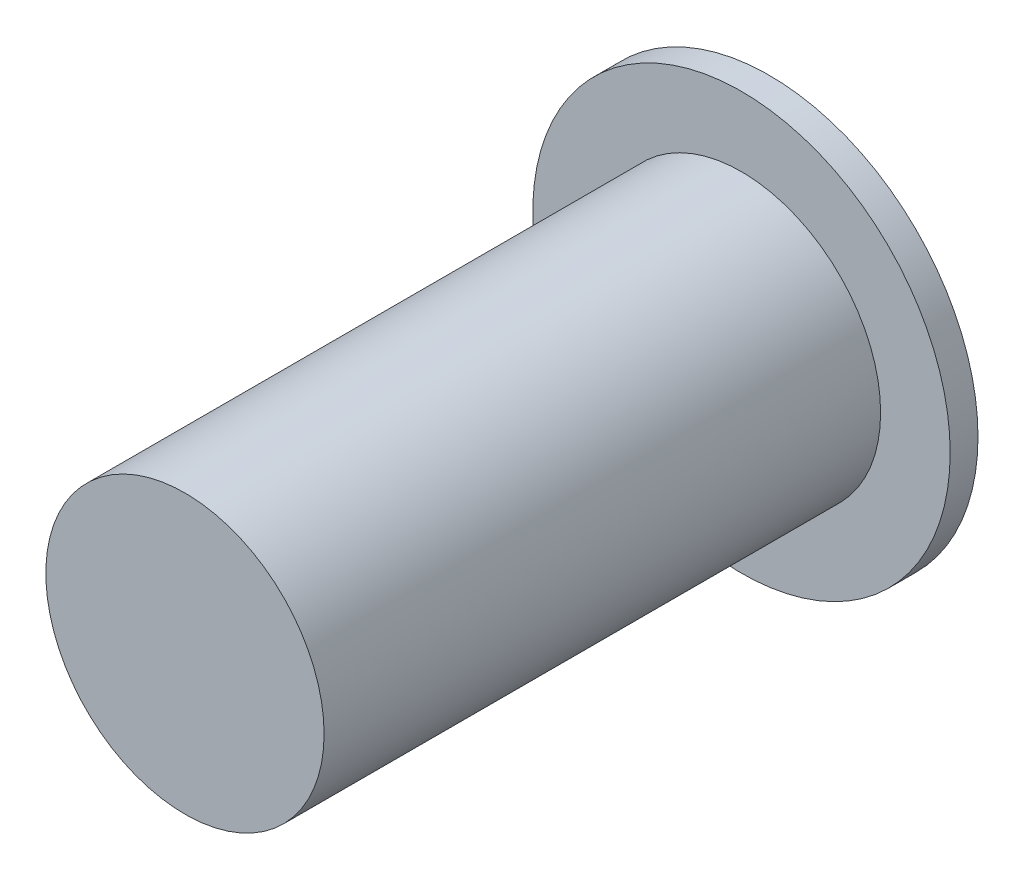
from build123d import *

# Parameters (mm, degrees)
CROQUIS1_R              = 0.75
SALIENTE_EXTRUIR1_DEPTH = 0.1
CROQUIS2_R              = 0.5
SALIENTE_EXTRUIR2_DEPTH = 2


with BuildPart() as part:
    # Croquis1 → Saliente-Extruir1 (new body)
    with BuildSketch(Plane.XY):
        Circle(CROQUIS1_R)
    extrude(amount=SALIENTE_EXTRUIR1_DEPTH)

    # Croquis2 → Saliente-Extruir2 (add)
    with BuildSketch(Plane.XY.offset(0.1)):
        Circle(CROQUIS2_R)
    extrude(amount=SALIENTE_EXTRUIR2_DEPTH)


solid = part.part
